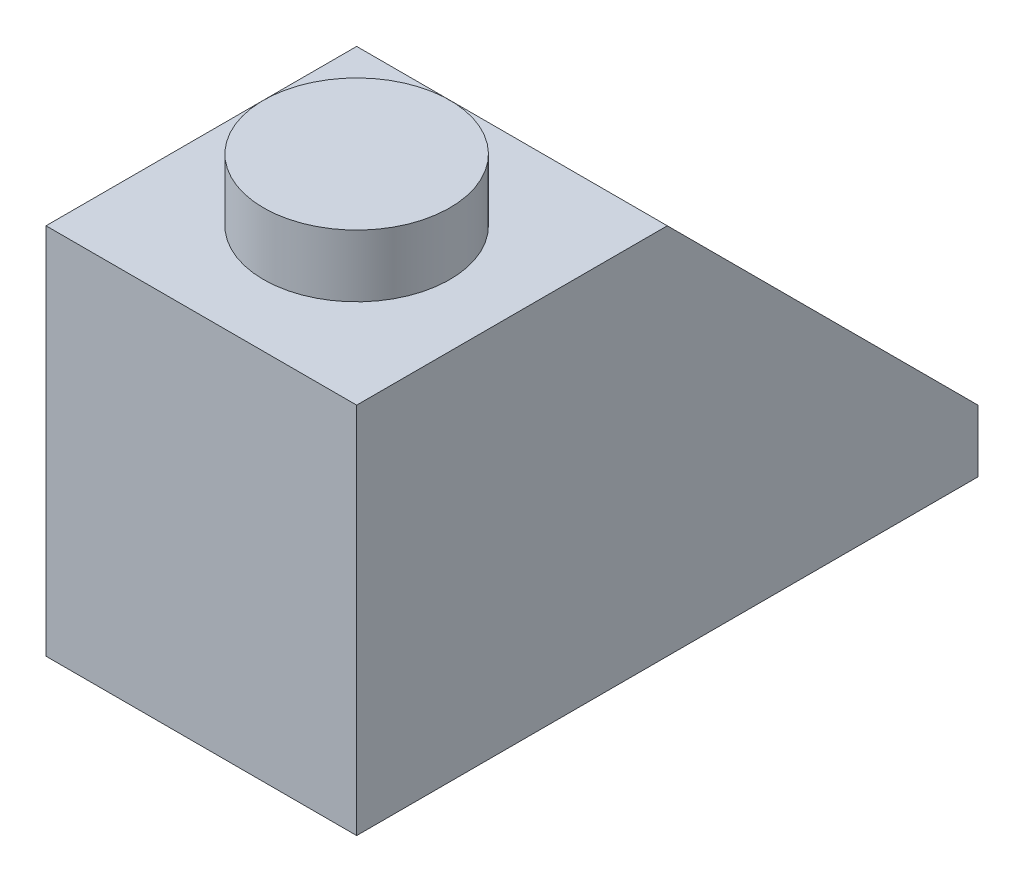
from build123d import *

# Parameters (mm, degrees)
BOSS_EXTRUDE2_DEPTH = 5
CUT_EXTRUDE1_DEPTH  = 4
BOSS_EXTRUDE3_DEPTH = 1
CUT_EXTRUDE2_REACH  = 14.689
SKETCH4_R           = 0.75
SKETCH4_4_R         = 1.5
SKETCH4_4_R_2       = 0.75
BOSS_EXTRUDE6_DEPTH = 1
SKETCH6_R           = 1
BOSS_EXTRUDE7_DEPTH = 5


with BuildPart() as part:
    # Sketch3 → Boss-Extrude2 (new body)
    with BuildSketch(Plane(origin=(0, 0, 0), x_dir=(0, 0, -1), z_dir=(1, 0, 0))):
        Polygon((5, 5), (4, 6), (1, 6), (0, 6), (0, 0), (1, 0), (1, 5), align=None)
        Polygon((9, 1), (5, 5), (1, 5), (1, 0), (9, 0), align=None)
        Polygon((10, 1), (5, 6), (4, 6), (5, 5), (9, 1), (9, 0), (10, 0), align=None)
    extrude(amount=BOSS_EXTRUDE2_DEPTH)

    # Sketch3_5 → Cut-Extrude1 (cut)
    with BuildSketch(Plane(origin=(0, 0, 0), x_dir=(0, 0, -1), z_dir=(1, 0, 0))):
        Polygon((9, 1), (5, 5), (1, 5), (1, 0), (9, 0), align=None)
    extrude(amount=CUT_EXTRUDE1_DEPTH, mode=Mode.SUBTRACT)

    # Sketch3_6 → Boss-Extrude3 (add)
    with BuildSketch(Plane(origin=(0, 0, 0), x_dir=(0, 0, -1), z_dir=(1, 0, 0))):
        Polygon((9, 1), (5, 5), (1, 5), (1, 0), (9, 0), align=None)
    extrude(amount=BOSS_EXTRUDE3_DEPTH)

    # Sketch4 → Cut-Extrude2 (cut, up to next)
    with BuildSketch(Plane(origin=(0, 6, 0), x_dir=(1, 0, 0), z_dir=(0, 1, 0)), mode=Mode.PRIVATE) as cut_extrude2_sk1:
        with Locations(Location((2.5, 2.5, 0), (0, 0, 270))):
            Circle(SKETCH4_R)
    cut_extrude2_tool1 = extrude(cut_extrude2_sk1.sketch, amount=-CUT_EXTRUDE2_REACH, mode=Mode.PRIVATE) & part.part
    add(cut_extrude2_tool1.solids().sort_by_distance((2.5, 6, -2.5))[0], mode=Mode.SUBTRACT)

    # Sketch4_4 → Boss-Extrude6 (add)
    with BuildSketch(Plane(origin=(0, 6, 0), x_dir=(1, 0, 0), z_dir=(0, 1, 0))):
        with Locations(Location((2.5, 2.5, 0), (0, 0, 270))):
            Circle(SKETCH4_4_R)
        with Locations(Location((2.5, 2.5, 0), (0, 0, 270))):
            Circle(SKETCH4_4_R_2, mode=Mode.SUBTRACT)
        with Locations(Location((2.5, 2.5, 0), (0, 0, 270))):
            Circle(SKETCH4_4_R_2)
    extrude(amount=BOSS_EXTRUDE6_DEPTH)

    # Sketch6 → Boss-Extrude7 (add)
    with BuildSketch(Plane(origin=(0, 5, 0), x_dir=(-1, 0, 0), z_dir=(0, -1, 0))):
        with Locations(Location((-2.5, 5, 0), (0, 0, 270))):
            Circle(SKETCH6_R)
    extrude(amount=BOSS_EXTRUDE7_DEPTH)


solid = part.part
